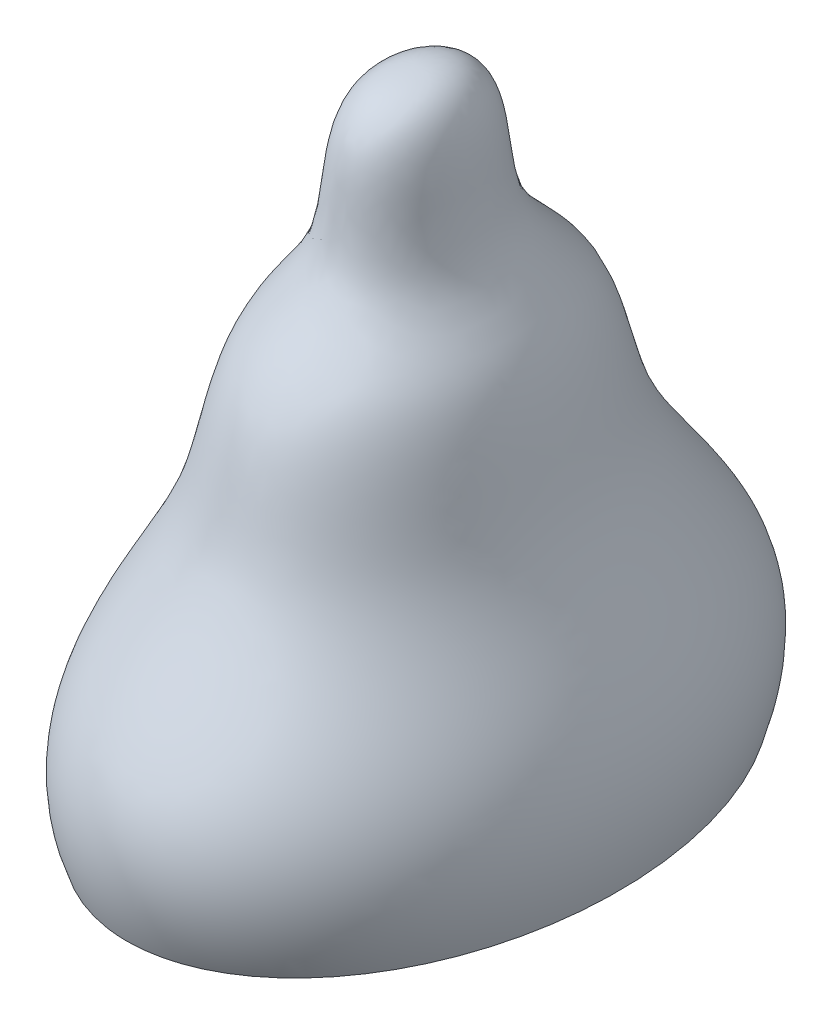
from build123d import *

# Parameters (mm, degrees)
SKALIEREN2_SCALE_X = 0.7
SKALIEREN2_SCALE_Y = 1
SKALIEREN2_SCALE_Z = 1


with BuildPart() as part:
    # Skizze2 → Rotation1 (revolve)
    with BuildSketch(Plane(origin=(0, 0, 0), x_dir=(0, 0, -1), z_dir=(1, 0, 0))):
        with BuildLine():
            Line((100, 0), (0, 0))
            Line((0, 0), (0, 212.407673465))
            add(Edge.make_bspline(
                [(100, 0), (117.702224528, 44.066597853), (64.62243788, 73.609319715), (59.300695133, 139.03865266), (17.217216686, 168.318291321), (32.784555432, 211.978696073), (0, 212.407673465)],
                knots=[0, 0, 0, 0, 0.424256426, 0.619048052, 0.743887986, 1, 1, 1, 1], degree=3))
        make_face()
    revolve(axis=Axis((0, 212.407673465, 0), (0, -1, 0)))


with BuildPart() as part_1:
    # Skalieren2: scaled about (0, 0, 0)
    add(part.part.scale((SKALIEREN2_SCALE_X, SKALIEREN2_SCALE_Y, SKALIEREN2_SCALE_Z), about=(0, 0, 0)))


solid = part_1.part
